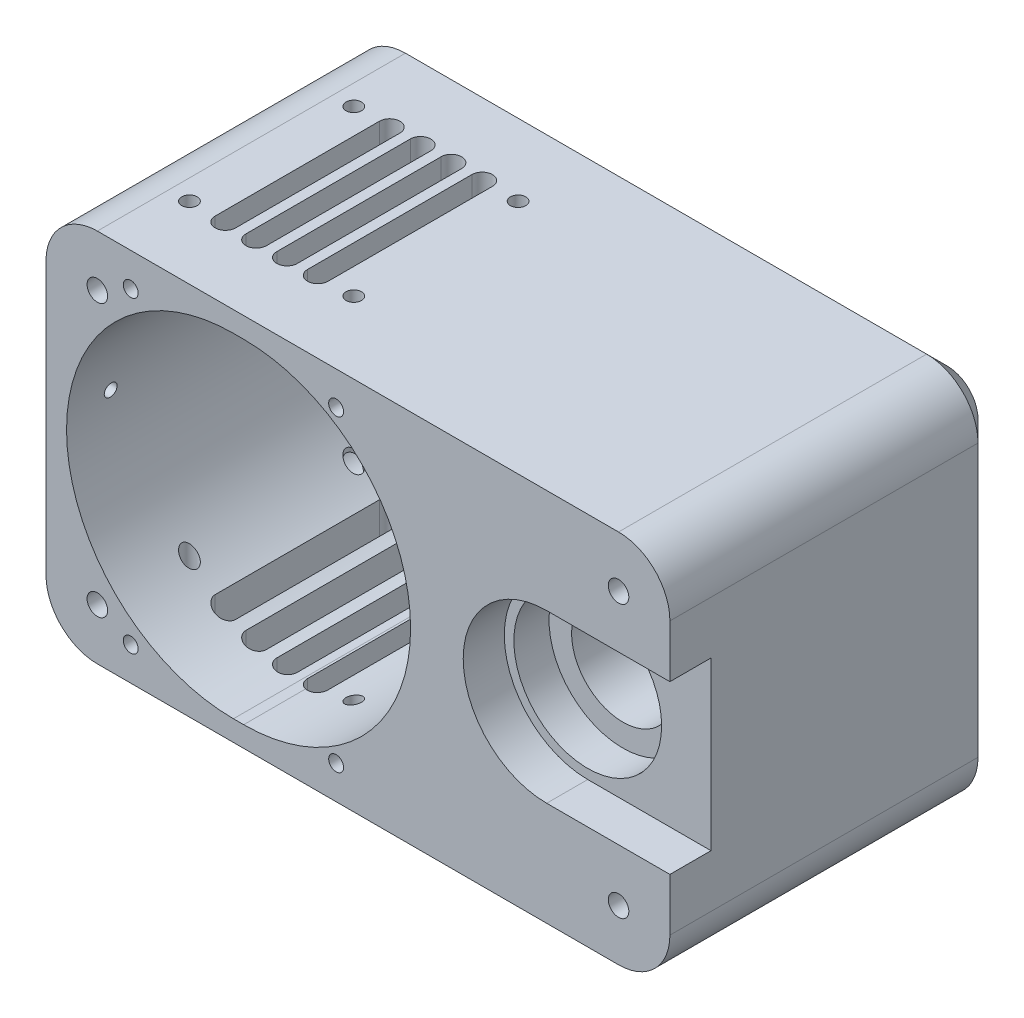
from build123d import *

# Parameters (mm, degrees)
SKETCH1_W           = 36.5
SKETCH1_H           = 73
BOSS_EXTRUDE1_DEPTH = 64
SKETCH2_R           = 32.5
CUT_EXTRUDE1_DEPTH  = 60
SKETCH3_R           = 10
CUT_EXTRUDE2_DEPTH  = 4
CUT_EXTRUDE10_DEPTH = 61
CHAMFER1_SIZE       = 4
FILLET1_R           = 10
SKETCH4_R           = 14.3875
CUT_EXTRUDE3_DEPTH  = 6.86
SKETCH5_R           = 10
CUT_EXTRUDE4_DEPTH  = 58.14
SKETCH6_R           = 16.25
CUT_EXTRUDE5_DEPTH  = 8
SKETCH7_R           = 14.3875
CUT_EXTRUDE6_DEPTH  = 6.85
CHAMFER5_SIZE       = 4
SKETCH9_R           = 2
CUT_EXTRUDE8_DEPTH  = 4
CUT_EXTRUDE9_DEPTH  = 65
SKETCH12_R          = 2
CUT_EXTRUDE11_DEPTH = 65
SKETCH13_R          = 4.5
CUT_EXTRUDE12_DEPTH = 40
CUT_EXTRUDE15_DEPTH = 20
SKETCH17_R          = 1.25
CUT_EXTRUDE16_DEPTH = 6
SKETCH19_R          = 1.25
CUT_EXTRUDE17_DEPTH = 5
SKETCH20_R          = 1.741609957
SKETCH20_R_2        = 2
CUT_EXTRUDE18_DEPTH = 8
SKETCH21_W          = 43.287705824
SKETCH21_H          = 32.5
CUT_EXTRUDE19_DEPTH = 8
SKETCH22_R          = 1.45
CUT_EXTRUDE20_DEPTH = 20
CUT_EXTRUDE21_DEPTH = 74
SKETCH24_R          = 1.5
CUT_EXTRUDE22_DEPTH = 74.0000001


with BuildPart() as part:
    # Sketch1 → Boss-Extrude1 (new body)
    with BuildSketch(Plane.XY):
        with BuildLine():
            ThreePointArc((36.5, 0), (25.809397513, 25.809397513), (0, 36.5))
            Line((0, 36.5), (0, -36.5))
            ThreePointArc((0, -36.5), (25.809397513, -25.809397513), (36.5, 0))
        make_face()
        with BuildLine():
            Line((0, -36.5), (0, 36.5))
            ThreePointArc((0, 36.5), (-25.809397513, 25.809397513), (-36.5, 0))
            ThreePointArc((-36.5, 0), (-25.809397513, -25.809397513), (0, -36.5))
        make_face()
        with BuildLine():
            ThreePointArc((36.5, 0), (25.809397513, 25.809397513), (0, 36.5))
            Line((0, 36.5), (0, -36.5))
            ThreePointArc((0, -36.5), (25.809397513, -25.809397513), (36.5, 0))
        make_face()
        with BuildLine():
            Line((0, -36.5), (0, 36.5))
            ThreePointArc((0, 36.5), (-25.809397513, 25.809397513), (-36.5, 0))
            ThreePointArc((-36.5, 0), (-25.809397513, -25.809397513), (0, -36.5))
        make_face()
        with BuildLine():
            Line((85, 36.5), (0, 36.5))
            ThreePointArc((0, 36.5), (25.809397513, 25.809397513), (36.5, 0))
            ThreePointArc((36.5, 0), (25.809397513, -25.809397513), (0, -36.5))
            Line((0, -36.5), (85, -36.5))
            Line((85, -36.5), (85, 36.5))
        make_face()
        with Locations((-18.25, 0)):
            Rectangle(SKETCH1_W, SKETCH1_H)
    extrude(amount=BOSS_EXTRUDE1_DEPTH)

    # Sketch2 → Cut-Extrude1 (cut)
    with BuildSketch(Plane.XY.offset(64)):
        Circle(SKETCH2_R)
    extrude(amount=-CUT_EXTRUDE1_DEPTH, mode=Mode.SUBTRACT)

    # Sketch3 → Cut-Extrude2 (cut)
    with BuildSketch(Plane(origin=(0, 0, 0), x_dir=(-1, 0, 0), z_dir=(0, 0, -1))):
        Circle(SKETCH3_R)
    extrude(amount=-CUT_EXTRUDE2_DEPTH, mode=Mode.SUBTRACT)

    # Sketch11 → Cut-Extrude10 (cut, through all)
    with BuildSketch(Plane.XY.offset(4)):
        with BuildLine():
            Line((0, 32.5), (2, 32.5))
            ThreePointArc((2, 32.5), (34.5, 0), (2, -32.5))
            Line((2, -32.5), (0, -32.5))
            ThreePointArc((0, -32.5), (-32.5, 0), (0, 32.5))
        make_face()
    extrude(amount=CUT_EXTRUDE10_DEPTH, mode=Mode.SUBTRACT)

    # Chamfer1
    chamfer1_edges = [part.edges().sort_by_distance(p)[0] for p in [
        (-32.5, 0, 4),
        (1, -32.5, 4),
        (34.5, 0, 4),
        (1, 32.5, 4),
    ]]
    chamfer(chamfer1_edges, length=CHAMFER1_SIZE)

    # Fillet1
    fillet1_edges = [part.edges().sort_by_distance(p)[0] for p in [
        (-36.5, 36.5, 32),
        (-36.5, -36.5, 32),
        (85, 36.5, 32),
        (85, -36.5, 32),
    ]]
    fillet(fillet1_edges, radius=FILLET1_R)

    # Sketch4 → Cut-Extrude3 (cut)
    with BuildSketch(Plane(origin=(0, 0, 0), x_dir=(-1, 0, 0), z_dir=(0, 0, -1))):
        with Locations((-61, 0)):
            Circle(SKETCH4_R)
    extrude(amount=-CUT_EXTRUDE3_DEPTH, mode=Mode.SUBTRACT)

    # Sketch5 → Cut-Extrude4 (cut, through all)
    with BuildSketch(Plane(origin=(0, 0, 6.86), x_dir=(-1, 0, 0), z_dir=(0, 0, -1))):
        with Locations((-61, 0)):
            Circle(SKETCH5_R)
    extrude(amount=-CUT_EXTRUDE4_DEPTH, mode=Mode.SUBTRACT)

    # Sketch6 → Cut-Extrude5 (cut)
    with BuildSketch(Plane.XY.offset(64)):
        with Locations((61, 0)):
            Circle(SKETCH6_R)
    extrude(amount=-CUT_EXTRUDE5_DEPTH, mode=Mode.SUBTRACT)

    # Sketch7 → Cut-Extrude6 (cut)
    with BuildSketch(Plane.XY.offset(56)):
        with Locations((61, 0)):
            Circle(SKETCH7_R)
    extrude(amount=-CUT_EXTRUDE6_DEPTH, mode=Mode.SUBTRACT)

    # Chamfer5
    chamfer5_edges = [part.edges().sort_by_distance(p)[0] for p in [
        (24.25, -36.5, 0),
        (-36.5, 0, 0),
        (24.25, 36.5, 0),
        (85, 0, 0),
        (82.071067812, 33.571067812, 0),
        (82.071067812, -33.571067812, 0),
        (-33.571067812, 33.571067812, 0),
        (-33.571067812, -33.571067812, 0),
    ]]
    chamfer(chamfer5_edges, length=CHAMFER5_SIZE)

    # Sketch9 → Cut-Extrude8 (cut)
    with BuildSketch(Plane(origin=(0, 0, 0), x_dir=(-1, 0, 0), z_dir=(0, 0, -1))):
        with Locations((15.622777965, 15.772406559)):
            Circle(SKETCH9_R)
        with Locations((10.696676805, 10.799125212)):
            Circle(SKETCH9_R)
        with Locations((10.799125212, -10.696676805)):
            Circle(SKETCH9_R)
        with Locations((15.772406559, -15.622777965)):
            Circle(SKETCH9_R)
        with Locations((-10.696676805, -10.799125212)):
            Circle(SKETCH9_R)
        with Locations((-15.622777965, -15.772406559)):
            Circle(SKETCH9_R)
        with Locations((-10.799125212, 10.696676805)):
            Circle(SKETCH9_R)
        with Locations((-15.772406559, 15.622777965)):
            Circle(SKETCH9_R)
    extrude(amount=-CUT_EXTRUDE8_DEPTH, mode=Mode.SUBTRACT)

    # Sketch10 → Cut-Extrude9 (cut, through all)
    with BuildSketch(Plane(origin=(0, 0, 0), x_dir=(-1, 0, 0), z_dir=(0, 0, -1))):
        with BuildLine():
            Line((15.622777965, 13.772406559), (13.622777965, 13.772406559))
            ThreePointArc((13.622777965, 13.772406559), (11.622777965, 15.772406559), (13.622777965, 17.772406559))
            Line((13.622777965, 17.772406559), (15.622777965, 17.772406559))
            ThreePointArc((15.622777965, 17.772406559), (17.622777965, 15.772406559), (15.622777965, 13.772406559))
        make_face()
        with BuildLine():
            Line((10.696676805, 8.799125212), (8.696676805, 8.799125212))
            ThreePointArc((8.696676805, 8.799125212), (6.696676805, 10.799125212), (8.696676805, 12.799125212))
            Line((8.696676805, 12.799125212), (10.696676805, 12.799125212))
            ThreePointArc((10.696676805, 12.799125212), (12.696676805, 10.799125212), (10.696676805, 8.799125212))
        make_face()
        with BuildLine():
            Line((15.772406559, -17.622777965), (13.772406559, -17.622777965))
            ThreePointArc((13.772406559, -17.622777965), (11.772406559, -15.622777965), (13.772406559, -13.622777965))
            Line((13.772406559, -13.622777965), (15.772406559, -13.622777965))
            ThreePointArc((15.772406559, -13.622777965), (17.772406559, -15.622777965), (15.772406559, -17.622777965))
        make_face()
        with BuildLine():
            Line((-10.696676805, -12.799125212), (-12.696676805, -12.799125212))
            ThreePointArc((-12.696676805, -12.799125212), (-14.696676805, -10.799125212), (-12.696676805, -8.799125212))
            Line((-12.696676805, -8.799125212), (-10.696676805, -8.799125212))
            ThreePointArc((-10.696676805, -8.799125212), (-8.696676805, -10.799125212), (-10.696676805, -12.799125212))
        make_face()
        with BuildLine():
            Line((-15.622777965, -17.772406559), (-17.622777965, -17.772406559))
            ThreePointArc((-17.622777965, -17.772406559), (-19.622777965, -15.772406559), (-17.622777965, -13.772406559))
            Line((-17.622777965, -13.772406559), (-15.622777965, -13.772406559))
            ThreePointArc((-15.622777965, -13.772406559), (-13.622777965, -15.772406559), (-15.622777965, -17.772406559))
        make_face()
        with BuildLine():
            Line((0, -10), (-2, -10))
            ThreePointArc((-2, -10), (-12, 0), (-2, 10))
            Line((-2, 10), (0, 10))
            ThreePointArc((0, 10), (10, 0), (0, -10))
        make_face()
        with BuildLine():
            Line((10.799125212, -12.696676805), (8.799125212, -12.696676805))
            ThreePointArc((8.799125212, -12.696676805), (6.799125212, -10.696676805), (8.799125212, -8.696676805))
            Line((8.799125212, -8.696676805), (10.799125212, -8.696676805))
            ThreePointArc((10.799125212, -8.696676805), (12.799125212, -10.696676805), (10.799125212, -12.696676805))
        make_face()
        with BuildLine():
            Line((-10.799125212, 8.696676805), (-12.799125212, 8.696676805))
            ThreePointArc((-12.799125212, 8.696676805), (-14.799125212, 10.696676805), (-12.799125212, 12.696676805))
            Line((-12.799125212, 12.696676805), (-10.799125212, 12.696676805))
            ThreePointArc((-10.799125212, 12.696676805), (-8.799125212, 10.696676805), (-10.799125212, 8.696676805))
        make_face()
        with BuildLine():
            Line((-15.772406559, 13.622777965), (-17.772406559, 13.622777965))
            ThreePointArc((-17.772406559, 13.622777965), (-19.772406559, 15.622777965), (-17.772406559, 17.622777965))
            Line((-17.772406559, 17.622777965), (-15.772406559, 17.622777965))
            ThreePointArc((-15.772406559, 17.622777965), (-13.772406559, 15.622777965), (-15.772406559, 13.622777965))
        make_face()
    extrude(amount=-CUT_EXTRUDE9_DEPTH, mode=Mode.SUBTRACT)

    # Sketch12 → Cut-Extrude11 (cut, through all)
    with BuildSketch(Plane.XY.offset(64)):
        with Locations((-26.5, -26.5)):
            Circle(SKETCH12_R)
        with Locations((-26.5, 26.5)):
            Circle(SKETCH12_R)
        with Locations((75, 26.5)):
            Circle(SKETCH12_R)
        with Locations((75, -26.5)):
            Circle(SKETCH12_R)
    extrude(amount=-CUT_EXTRUDE11_DEPTH, mode=Mode.SUBTRACT)

    # Sketch13 → Cut-Extrude12 (cut)
    with BuildSketch(Plane(origin=(0, 0, 0), x_dir=(-1, 0, 0), z_dir=(0, 0, -1))):
        with Locations((-75, 26.5)):
            Circle(SKETCH13_R)
        with Locations((-75, -26.5)):
            Circle(SKETCH13_R)
        with Locations((26.5, -26.5)):
            Circle(SKETCH13_R)
        with Locations((26.5, 26.5)):
            Circle(SKETCH13_R)
    extrude(amount=-CUT_EXTRUDE12_DEPTH, mode=Mode.SUBTRACT)

    # Sketch16 → Cut-Extrude15 (cut)
    with BuildSketch(Plane.ZY.offset(36.5)):
        with BuildLine():
            Line((13, 7.5), (13, -7.5))
            ThreePointArc((13, -7.5), (9, -11.5), (5, -7.5))
            Line((5, -7.5), (5, 7.5))
            ThreePointArc((5, 7.5), (9, 11.5), (13, 7.5))
        make_face()
    extrude(amount=-CUT_EXTRUDE15_DEPTH, mode=Mode.SUBTRACT)

    # Sketch17 → Cut-Extrude16 (cut)
    with BuildSketch(Plane.ZY.offset(36.5)):
        with Locations((28.5, 21.5)):
            Circle(SKETCH17_R)
        with Locations((55.5, 21.5)):
            Circle(SKETCH17_R)
        with Locations((28.5, 2.5)):
            Circle(SKETCH17_R)
        with Locations((55.5, 2.5)):
            Circle(SKETCH17_R)
    extrude(amount=-CUT_EXTRUDE16_DEPTH, mode=Mode.SUBTRACT)

    # Sketch19 → Cut-Extrude17 (cut)
    with BuildSketch(Plane.XZ.offset(36.5)):
        with Locations((35, 51)):
            Circle(SKETCH19_R)
        with Locations((35, 24)):
            Circle(SKETCH19_R)
        with Locations((16, 51)):
            Circle(SKETCH19_R)
        with Locations((16, 24)):
            Circle(SKETCH19_R)
    extrude(amount=-CUT_EXTRUDE17_DEPTH, mode=Mode.SUBTRACT)

    # Sketch20 → Cut-Extrude18 (cut)
    with BuildSketch(Plane(origin=(0, 0, 0), x_dir=(-1, 0, 0), z_dir=(0, 0, -1))):
        with Locations((-5.5, 30.5)):
            Circle(SKETCH20_R)
        with Locations((-5.5, -30.5)):
            Circle(SKETCH20_R_2)
    extrude(amount=-CUT_EXTRUDE18_DEPTH, mode=Mode.SUBTRACT)

    # Sketch21 → Cut-Extrude19 (cut)
    with BuildSketch(Plane.XY.offset(64)):
        with Locations((82.643852912, 0)):
            Rectangle(SKETCH21_W, SKETCH21_H)
    extrude(amount=-CUT_EXTRUDE19_DEPTH, mode=Mode.SUBTRACT)

    # Sketch22 → Cut-Extrude20 (cut)
    with BuildSketch(Plane.XY.offset(64)):
        with Locations((-20, 30)):
            Circle(SKETCH22_R)
        with Locations((20, 30)):
            Circle(SKETCH22_R)
        with Locations((20, -30)):
            Circle(SKETCH22_R)
        with Locations((-20, -30)):
            Circle(SKETCH22_R)
    extrude(amount=-CUT_EXTRUDE20_DEPTH, mode=Mode.SUBTRACT)

    # Sketch23 → Cut-Extrude21 (cut, through all)
    with BuildSketch(Plane.XZ.offset(36.5)):
        with BuildLine():
            Line((-13.562189741, 50), (-13.562189741, 18))
            ThreePointArc((-13.562189741, 18), (-15.562189741, 16), (-17.562189741, 18))
            Line((-17.562189741, 18), (-17.562189741, 50))
            ThreePointArc((-17.562189741, 50), (-15.562189741, 52), (-13.562189741, 50))
        make_face()
        with BuildLine():
            Line((-7.562189741, 50), (-7.562189741, 18))
            ThreePointArc((-7.562189741, 18), (-9.562189741, 16), (-11.562189741, 18))
            Line((-11.562189741, 18), (-11.562189741, 50))
            ThreePointArc((-11.562189741, 50), (-9.562189741, 52), (-7.562189741, 50))
        make_face()
        with BuildLine():
            Line((-1.562189741, 50), (-1.562189741, 18))
            ThreePointArc((-1.562189741, 18), (-3.562189741, 16), (-5.562189741, 18))
            Line((-5.562189741, 18), (-5.562189741, 50))
            ThreePointArc((-5.562189741, 50), (-3.562189741, 52), (-1.562189741, 50))
        make_face()
        with BuildLine():
            Line((4.437810259, 50), (4.437810259, 18))
            ThreePointArc((4.437810259, 18), (2.437810259, 16), (0.437810259, 18))
            Line((0.437810259, 18), (0.437810259, 50))
            ThreePointArc((0.437810259, 50), (2.437810259, 52), (4.437810259, 50))
        make_face()
    extrude(amount=-CUT_EXTRUDE21_DEPTH, mode=Mode.SUBTRACT)

    # Sketch24 → Cut-Extrude22 (cut, through all)
    with BuildSketch(Plane(origin=(0, 36.5, 0), x_dir=(1, 0, 0), z_dir=(0, 1, 0))):
        with Locations((-22.562189741, -18)):
            Circle(SKETCH24_R)
        with Locations((-22.562189741, -50)):
            Circle(SKETCH24_R)
        with Locations((9.437810259, -18)):
            Circle(SKETCH24_R)
        with Locations((9.437810259, -50)):
            Circle(SKETCH24_R)
    extrude(amount=-CUT_EXTRUDE22_DEPTH, mode=Mode.SUBTRACT)


solid = part.part
